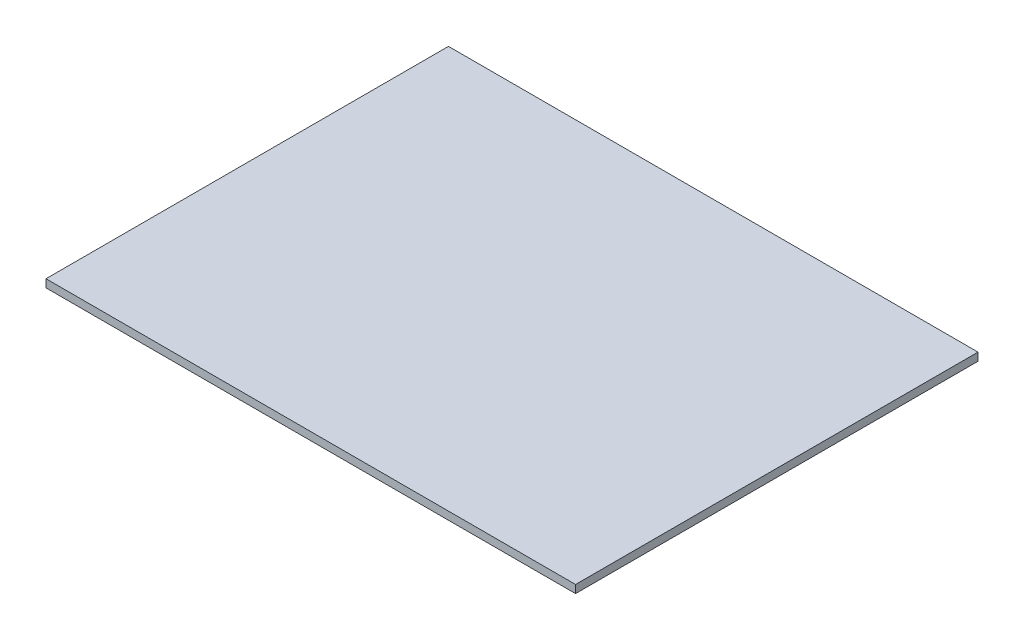
from build123d import *

# Parameters (mm, degrees)
SKETCH1_W           = 100
SKETCH1_H           = 76
BOSS_EXTRUDE1_DEPTH = 1.5


with BuildPart() as part:
    # Sketch1 → Boss-Extrude1 (new body)
    with BuildSketch(Plane(origin=(0, 0, 0), x_dir=(1, 0, 0), z_dir=(0, 1, 0))):
        with Locations((-50, 38)):
            Rectangle(SKETCH1_W, SKETCH1_H)
    extrude(amount=BOSS_EXTRUDE1_DEPTH)


solid = part.part
